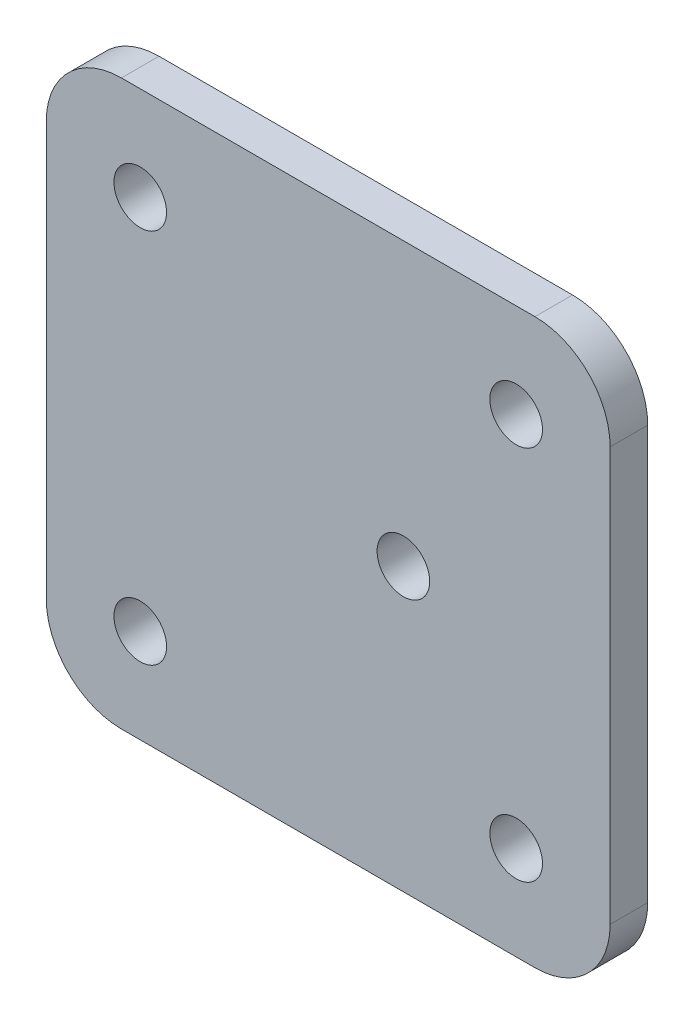
from build123d import *

# Parameters (mm, degrees)
SKETCH1_W                = 75
SKETCH1_H                = 75
BOSS_EXTRUDE1_DEPTH      = 5
F_7_0_7_DIAMETER_HOLE2_D = 7
FILLET1_R                = 10
F_7_0_7_DIAMETER_HOLE1_D = 7


with BuildPart() as part:
    # Sketch1 → Boss-Extrude1 (new body)
    with BuildSketch(Plane.XY):
        Rectangle(SKETCH1_W, SKETCH1_H)
    extrude(amount=BOSS_EXTRUDE1_DEPTH)

    # Ø7.0 (7) Diameter Hole2 (through all)
    with Locations(Plane.XY.offset(5)):
        with Locations((-25, 25), (-25, -25), (25, -25), (25, 25)):
            Hole(F_7_0_7_DIAMETER_HOLE2_D / 2)

    # Fillet1
    fillet1_edges = [part.edges().sort_by_distance(p)[0] for p in [
        (-37.5, 37.5, 2.5),
        (37.5, 37.5, 2.5),
        (37.5, -37.5, 2.5),
        (-37.5, -37.5, 2.5),
    ]]
    fillet(fillet1_edges, radius=FILLET1_R)

    # Ø7.0 (7) Diameter Hole1 (through all)
    with Locations(Plane.XY.offset(5)):
        with Locations((10, 0)):
            Hole(F_7_0_7_DIAMETER_HOLE1_D / 2)


solid = part.part
